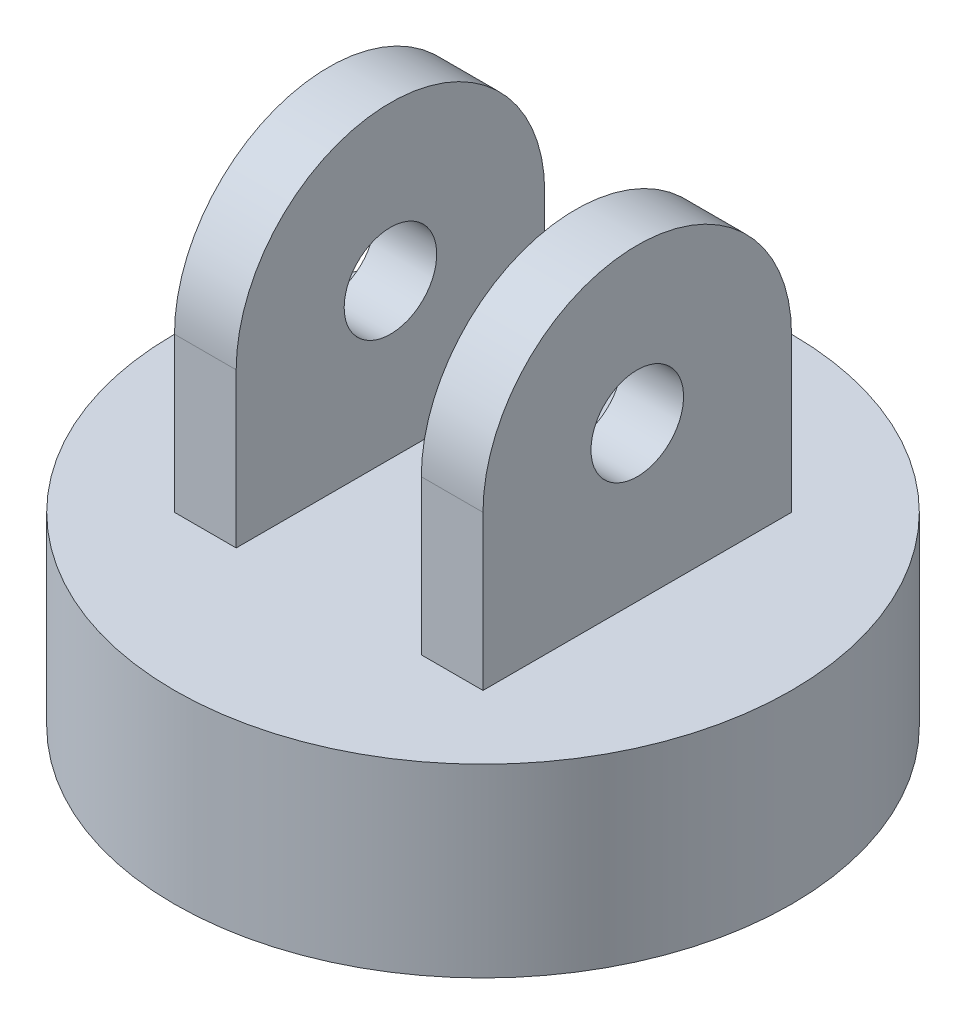
from build123d import *

# Parameters (mm, degrees)
SKETCH1_R           = 50
BOSS_EXTRUDE1_DEPTH = 30
SKETCH2_W           = 10
SKETCH2_H           = 50
BOSS_EXTRUDE2_DEPTH = 50
CUT_EXTRUDE2_DEPTH  = 50
SKETCH5_R           = 7.5
CUT_EXTRUDE3_DEPTH  = 50


with BuildPart() as part:
    # Sketch1 → Boss-Extrude1 (new body)
    with BuildSketch(Plane(origin=(0, 0, 0), x_dir=(1, 0, 0), z_dir=(0, 1, 0))):
        Circle(SKETCH1_R)
    extrude(amount=BOSS_EXTRUDE1_DEPTH)

    # Sketch2 → Boss-Extrude2 (add)
    with BuildSketch(Plane(origin=(0, 30, 0), x_dir=(1, 0, 0), z_dir=(0, 1, 0))):
        with Locations((-20, 0)):
            Rectangle(SKETCH2_W, SKETCH2_H)
        with Locations((20, 0)):
            Rectangle(SKETCH2_W, SKETCH2_H)
    extrude(amount=BOSS_EXTRUDE2_DEPTH)

    # Sketch4 → Cut-Extrude2 (cut)
    with BuildSketch(Plane.ZY.offset(25)):
        with BuildLine():
            Line((30.852726851, 88.254535322), (30.852726851, 55))
            Line((30.852726851, 55), (25, 55))
            ThreePointArc((25, 55), (0, 80), (-25, 55))
            Line((-25, 55), (-34.201839493, 55))
            Line((-34.201839493, 55), (-34.201839493, 88.254535322))
            Line((-34.201839493, 88.254535322), (30.852726851, 88.254535322))
        make_face()
    extrude(amount=-CUT_EXTRUDE2_DEPTH, mode=Mode.SUBTRACT)

    # Sketch5 → Cut-Extrude3 (cut)
    with BuildSketch(Plane.ZY.offset(25)):
        with Locations((0, 55)):
            Circle(SKETCH5_R)
    extrude(amount=-CUT_EXTRUDE3_DEPTH, mode=Mode.SUBTRACT)


solid = part.part
